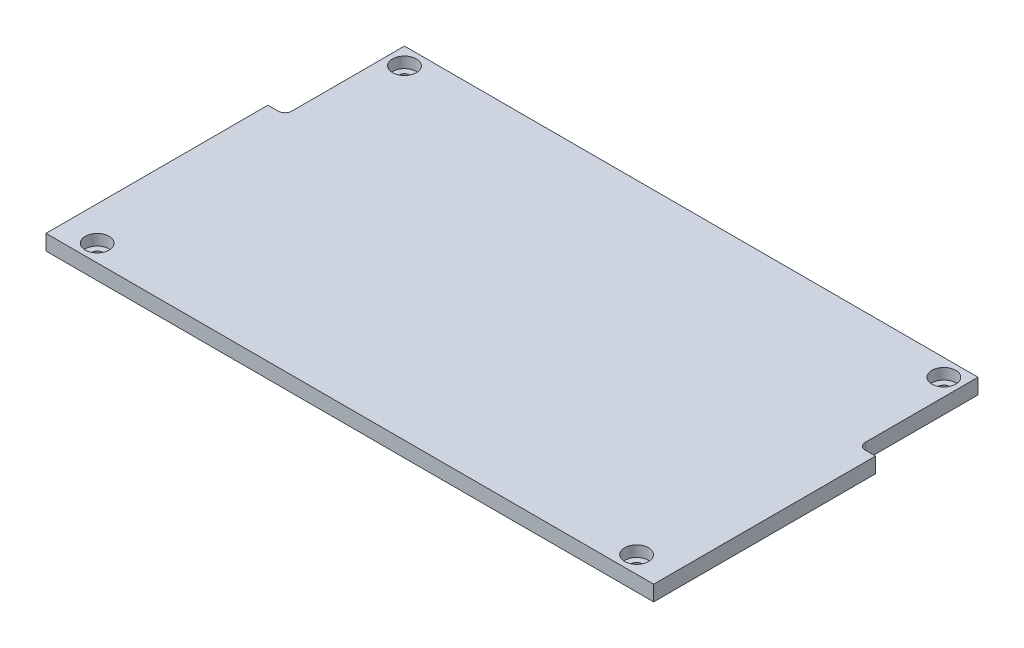
from build123d import *

# Parameters (mm, degrees)
SKIZZE1_W                                            = 89
SKIZZE1_H                                            = 50
AUFSATZ_LINEAR_AUSTRAGEN1_DEPTH                      = 4.5
SKIZZE3_W                                            = 16
SKIZZE3_H                                            = 12
SCHNITT_LINEAR_AUSTRAGEN2_DEPTH                      = 5.5
VERRUNDUNG1_R                                        = 2
LINEARES_MUSTER1_COUNT                               = 3
LINEARES_MUSTER1_PITCH                               = 16
LINEARES_MUSTER1_COUNT_DIR2                          = 4
LINEARES_MUSTER1_PITCH_DIR2                          = 20
VERRUNDUNG1_OF_LINEARES_MUSTER1_R                    = 2
SKIZZE2_R                                            = 5
AUFSATZ_LINEAR_AUSTRAGEN2_DEPTH                      = 4.5
STIRNSENKUNG_F_R_M3_FLACHKOPFSCHRAUBE_MI_D           = 3.4
STIRNSENKUNG_F_R_M3_FLACHKOPFSCHRAUBE_MI_CBORE_D     = 7
STIRNSENKUNG_F_R_M3_FLACHKOPFSCHRAUBE_MI_CBORE_DEPTH = 3.2
VERRUNDUNG3_R                                        = 3
SCHNITT_LINEAR_AUSTRAGEN3_DEPTH                      = 1.5
AUFSATZ_LINEAR_AUSTRAGEN3_DEPTH                      = 3
SKIZZE8_W                                            = 10
SKIZZE8_H                                            = 35
SCHNITT_LINEAR_AUSTRAGEN4_DEPTH                      = 5.5
VERRUNDUNG4_R                                        = 2


with BuildPart() as part:
    # Skizze1 → Aufsatz-Linear austragen1 (new body)
    with BuildSketch(Plane(origin=(0, 0, 0), x_dir=(1, 0, 0), z_dir=(0, 1, 0))):
        with Locations((-44.5, 25)):
            Rectangle(SKIZZE1_W, SKIZZE1_H)
    extrude(amount=AUFSATZ_LINEAR_AUSTRAGEN1_DEPTH)

    # Skizze3 → Schnitt-Linear austragen2 (cut, through all)
    with BuildSketch(Plane(origin=(0, 4.5, 0), x_dir=(1, 0, 0), z_dir=(0, 1, 0))):
        with Locations((-11, 9)):
            Rectangle(SKIZZE3_W, SKIZZE3_H)
    schnitt_linear_austragen2 = extrude(amount=-SCHNITT_LINEAR_AUSTRAGEN2_DEPTH, mode=Mode.SUBTRACT)

    # Verrundung1
    verrundung1_edges = [part.edges().sort_by_distance(p)[0] for p in [
        (-3, 2.25, -15),
        (-3, 2.25, -3),
        (-19, 2.25, -3),
        (-19, 2.25, -15),
    ]]
    fillet(verrundung1_edges, radius=VERRUNDUNG1_R)

    # Lineares Muster1: Schnitt-Linear austragen2 3 × 4
    with Locations(*[(-j * LINEARES_MUSTER1_PITCH_DIR2, 0, -i * LINEARES_MUSTER1_PITCH) for i in range(LINEARES_MUSTER1_COUNT) for j in range(LINEARES_MUSTER1_COUNT_DIR2) if (i, j) != (0, 0)]):
        add(schnitt_linear_austragen2, mode=Mode.SUBTRACT)

    # Verrundung1 of Lineares Muster1
    verrundung1_of_lineares_muster1_edges = [part.edges().sort_by_distance(p)[0] for p in [
        (-23, 2.25, -15),
        (-23, 2.25, -3),
        (-39, 2.25, -3),
        (-39, 2.25, -15),
        (-43, 2.25, -15),
        (-43, 2.25, -3),
        (-59, 2.25, -3),
        (-59, 2.25, -15),
        (-63, 2.25, -15),
        (-63, 2.25, -3),
        (-79, 2.25, -3),
        (-79, 2.25, -15),
        (-3, 2.25, -31),
        (-3, 2.25, -19),
        (-19, 2.25, -19),
        (-19, 2.25, -31),
        (-23, 2.25, -31),
        (-23, 2.25, -19),
        (-39, 2.25, -19),
        (-39, 2.25, -31),
        (-43, 2.25, -31),
        (-43, 2.25, -19),
        (-59, 2.25, -19),
        (-59, 2.25, -31),
        (-63, 2.25, -31),
        (-63, 2.25, -19),
        (-79, 2.25, -19),
        (-79, 2.25, -31),
        (-3, 2.25, -47),
        (-3, 2.25, -35),
        (-19, 2.25, -35),
        (-19, 2.25, -47),
        (-23, 2.25, -47),
        (-23, 2.25, -35),
        (-39, 2.25, -35),
        (-39, 2.25, -47),
        (-43, 2.25, -47),
        (-43, 2.25, -35),
        (-59, 2.25, -35),
        (-59, 2.25, -47),
        (-63, 2.25, -47),
        (-63, 2.25, -35),
        (-79, 2.25, -35),
        (-79, 2.25, -47),
    ]]
    fillet(verrundung1_of_lineares_muster1_edges, radius=VERRUNDUNG1_OF_LINEARES_MUSTER1_R)

    # Skizze2 → Aufsatz-Linear austragen2 (add)
    with BuildSketch(Plane(origin=(0, 4.5, 0), x_dir=(1, 0, 0), z_dir=(0, 1, 0))):
        with Locations((-79, 45)):
            Circle(SKIZZE2_R)
    extrude(amount=-AUFSATZ_LINEAR_AUSTRAGEN2_DEPTH)

    # Stirnsenkung für M3 Flachkopfschraube mit Schlitz1 (through all)
    with Locations(Plane(origin=(0, 4.5, 0), x_dir=(1, 0, 0), z_dir=(0, 1, 0))):
        with Locations((-79, 45)):
            CounterBoreHole(STIRNSENKUNG_F_R_M3_FLACHKOPFSCHRAUBE_MI_D / 2, STIRNSENKUNG_F_R_M3_FLACHKOPFSCHRAUBE_MI_CBORE_D / 2, STIRNSENKUNG_F_R_M3_FLACHKOPFSCHRAUBE_MI_CBORE_DEPTH)

    # Verrundung3
    verrundung3_edges = [part.edges().sort_by_distance(p)[0] for p in [
        (-74.417424305, 2.25, -47),
        (-79, 2.25, -40),
    ]]
    fillet(verrundung3_edges, radius=VERRUNDUNG3_R)

    # Skizze6 → Schnitt-Linear austragen3 (cut)
    with BuildSketch(Plane.XZ):
        Polygon((0, 0), (-79, 0), (-79, -37), (-71.062746067, -37), (-71.062746067, -47), (0, -47), align=None)
    extrude(amount=-SCHNITT_LINEAR_AUSTRAGEN3_DEPTH, mode=Mode.SUBTRACT)

    # Skizze7 → Aufsatz-Linear austragen3 (add)
    with BuildSketch(Plane.XZ.offset(-1.5)):
        with BuildLine():
            Line((-79, 0), (0, 0))
            Line((0, 0), (0, -47))
            Line((0, -47), (-71.062746067, -47))
            ThreePointArc((-71.062746067, -47), (-73.04705955, -46.25), (-74.039216292, -44.375))
            ThreePointArc((-74.039216292, -44.375), (-75.037392467, -41.950780175), (-77.125, -40.364875946))
            ThreePointArc((-77.125, -40.364875946), (-78.487468593, -39.260852496), (-79, -37.583801513))
            Line((-79, -37.583801513), (-79, 0))
        make_face()
    extrude(amount=-AUFSATZ_LINEAR_AUSTRAGEN3_DEPTH)

    # Spiegeln1: part across plane


with BuildPart() as part_1:
    add(part.part)
    add(part.part.mirror(Plane(origin=(0, 4.5, 0), x_dir=(1, 0, 0), z_dir=(0, 0, -1))))

    # Skizze8 → Schnitt-Linear austragen4 (cut, through all)
    with BuildSketch(Plane.XZ):
        with Locations((-89, -32.5)):
            Rectangle(SKIZZE8_W, SKIZZE8_H)
    extrude(amount=-SCHNITT_LINEAR_AUSTRAGEN4_DEPTH, mode=Mode.SUBTRACT)

    # Verrundung4
    verrundung4_edges = [part_1.edges().sort_by_distance(p)[0] for p in [
        (-84, 2.25, -15),
    ]]
    fillet(verrundung4_edges, radius=VERRUNDUNG4_R)

    # Spiegeln2: part across plane


with BuildPart() as part_2:
    add(part_1.part)
    add(part_1.part.mirror(Plane(origin=(0, 4.5, 0), x_dir=(0, 0, 1), z_dir=(-1, 0, 0))))


solid = part_2.part
